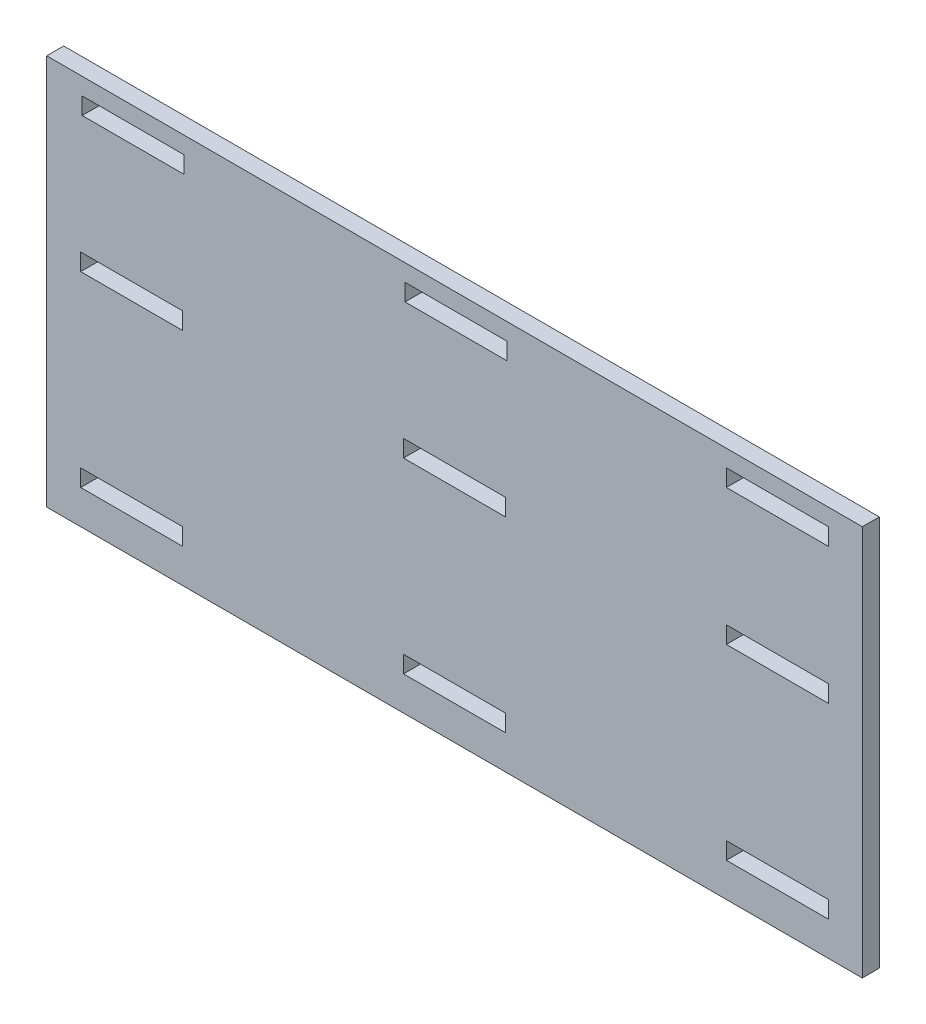
from build123d import *

# Parameters (mm, degrees)
SKETCH2_W           = 240
SKETCH2_H           = 115
SKETCH2_W_2         = 30
SKETCH2_H_2         = 5
BOSS_EXTRUDE1_DEPTH = 5


with BuildPart() as part:
    # Sketch2 → Boss-Extrude1 (new body)
    with BuildSketch(Plane.XY):
        Rectangle(SKETCH2_W, SKETCH2_H)
        with Locations((-94.565217391, 50)):
            Rectangle(SKETCH2_W_2, SKETCH2_H_2, mode=Mode.SUBTRACT)
        with Locations((0.434782609, 50)):
            Rectangle(SKETCH2_W_2, SKETCH2_H_2, mode=Mode.SUBTRACT)
        with Locations((95, 50)):
            Rectangle(SKETCH2_W_2, SKETCH2_H_2, mode=Mode.SUBTRACT)
        with Locations((-95, 10)):
            Rectangle(SKETCH2_W_2, SKETCH2_H_2, mode=Mode.SUBTRACT)
        with Locations((0, 10)):
            Rectangle(SKETCH2_W_2, SKETCH2_H_2, mode=Mode.SUBTRACT)
        with Locations((95, 10)):
            Rectangle(SKETCH2_W_2, SKETCH2_H_2, mode=Mode.SUBTRACT)
        with Locations((-95, -45)):
            Rectangle(SKETCH2_W_2, SKETCH2_H_2, mode=Mode.SUBTRACT)
        with Locations((0, -45)):
            Rectangle(SKETCH2_W_2, SKETCH2_H_2, mode=Mode.SUBTRACT)
        with Locations((95, -45)):
            Rectangle(SKETCH2_W_2, SKETCH2_H_2, mode=Mode.SUBTRACT)
    extrude(amount=BOSS_EXTRUDE1_DEPTH)


solid = part.part
